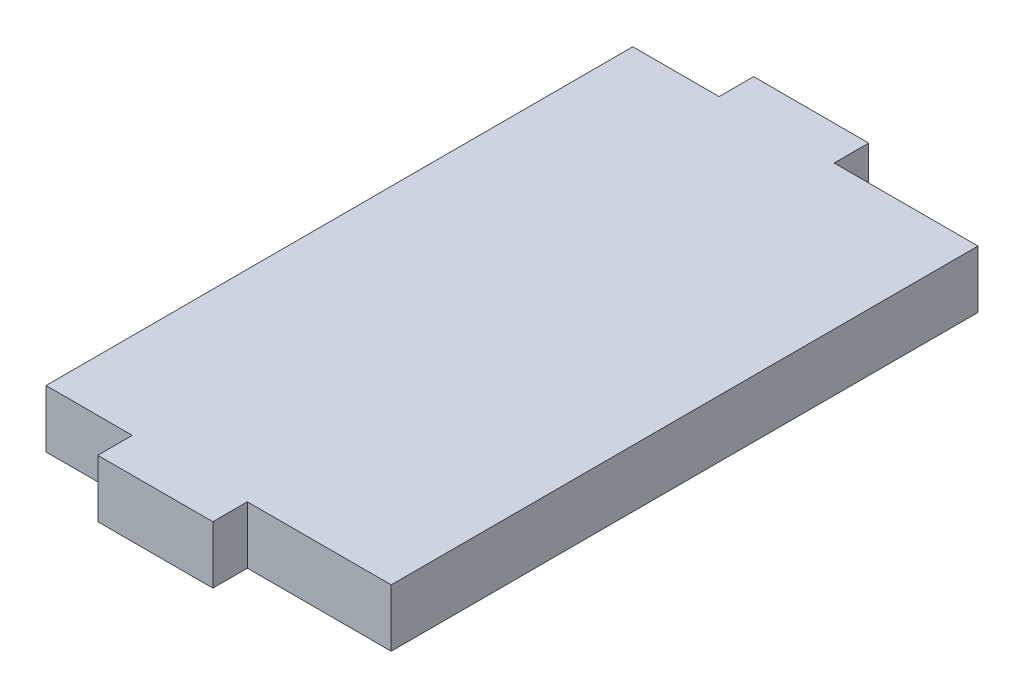
from build123d import *

# Parameters (mm, degrees)
BOSS_EXTRU_1_DEPTH = 5


with BuildPart() as part:
    # Esquisse1 → Boss.-Extru.1 (new body)
    with BuildSketch(Plane(origin=(0, 0, 0), x_dir=(1, 0, 0), z_dir=(0, 1, 0))):
        Polygon((15, 25.5), (2.5, 25.5), (2.5, 28.5), (-7.5, 28.5), (-7.5, 25.5), (-15, 25.5), (-15, -25.5), (-7.5, -25.5), (-7.5, -28.5), (2.5, -28.5), (2.5, -25.5), (15, -25.5), align=None)
    extrude(amount=BOSS_EXTRU_1_DEPTH)


solid = part.part
